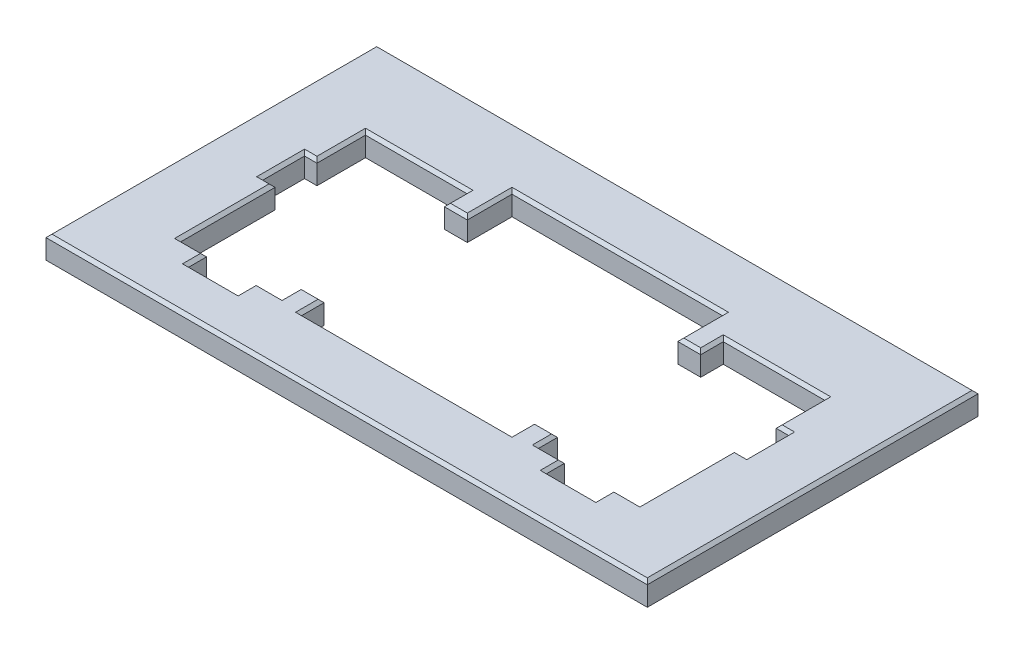
from build123d import *

# Parameters (mm, degrees)
SKETCH1_W           = 40
SKETCH1_H           = 22
BOSS_EXTRUDE1_DEPTH = 1.5
CUT_EXTRUDE1_DEPTH  = 2.5
CHAMFER1_SIZE       = 0.2


with BuildPart() as part:
    # Sketch1 → Boss-Extrude1 (new body)
    with BuildSketch(Plane(origin=(0, 0, 0), x_dir=(1, 0, 0), z_dir=(0, 1, 0))):
        Rectangle(SKETCH1_W, SKETCH1_H)
    extrude(amount=BOSS_EXTRUDE1_DEPTH)

    # Sketch2 → Cut-Extrude1 (cut, through all)
    with BuildSketch(Plane(origin=(0, 1.5, 0), x_dir=(1, 0, 0), z_dir=(0, 1, 0))):
        Polygon((-7, 4.03), (-8.525, 4.03), (-8.525, 5.53), (-15.275, 5.53), (-15.275, 2.3), (-16.1, 2.3), (-16.1, -0.485), (-15.275, -0.485), (-15.275, -6.77), (-13.55, -6.77), (-13.55, -7.97), (-10.25, -7.97), (-10.25, -6.77), (-8.525, -6.77), (-8.525, -5.5), (-7, -5.5), (-7, -7), (7, -7), (7, -5.5), (8.525, -5.5), (8.525, -6.77), (10.25, -6.77), (10.25, -7.97), (13.55, -7.97), (13.55, -6.77), (15.275, -6.77), (15.275, -0.485), (16.1, -0.485), (16.1, 2.3), (15.275, 2.3), (15.275, 5.53), (8.525, 5.53), (8.525, 4.03), (7, 4.03), (7, 7), (-7, 7), align=None)
    extrude(amount=-CUT_EXTRUDE1_DEPTH, mode=Mode.SUBTRACT)

    # Chamfer1
    chamfer1_edges = [part.edges().sort_by_distance(p)[0] for p in [
        (-20, 1.5, 0),
        (0, 1.5, 11),
        (20, 1.5, 0),
        (7, 1.5, 6.25),
        (7.7625, 1.5, 5.5),
        (8.525, 1.5, 6.135),
        (9.3875, 1.5, 6.77),
        (10.25, 1.5, 7.37),
        (11.9, 1.5, 7.97),
        (13.55, 1.5, 7.37),
        (14.4125, 1.5, 6.77),
        (15.275, 1.5, 3.6275),
        (15.6875, 1.5, 0.485),
        (16.1, 1.5, -0.9075),
        (15.6875, 1.5, -2.3),
        (15.275, 1.5, -3.915),
        (11.9, 1.5, -5.53),
        (8.525, 1.5, -4.78),
        (7.7625, 1.5, -4.03),
        (7, 1.5, -5.515),
        (0, 1.5, -7),
        (-7, 1.5, -5.515),
        (-7.7625, 1.5, -4.03),
        (-8.525, 1.5, -4.78),
        (-11.9, 1.5, -5.53),
        (-15.275, 1.5, -3.915),
        (-15.6875, 1.5, -2.3),
        (-16.1, 1.5, -0.9075),
        (-15.6875, 1.5, 0.485),
        (-15.275, 1.5, 3.6275),
        (-14.4125, 1.5, 6.77),
        (-13.55, 1.5, 7.37),
        (-11.9, 1.5, 7.97),
        (-10.25, 1.5, 7.37),
        (-9.3875, 1.5, 6.77),
        (-8.525, 1.5, 6.135),
        (-7.7625, 1.5, 5.5),
        (-7, 1.5, 6.25),
        (0, 1.5, 7),
        (0, 1.5, -11),
    ]]
    chamfer(chamfer1_edges, length=CHAMFER1_SIZE)


solid = part.part
